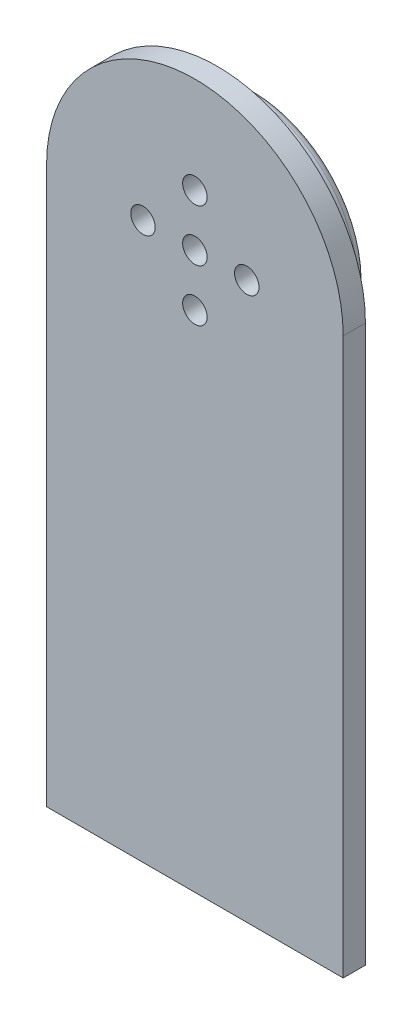
from build123d import *

# Parameters (mm, degrees)
SKETCH_1_R      = 15
SKETCH_1_R_2    = 1.65
EXTRUDE_1_DEPTH = 8
FILLET_1_R      = 1
EXTRUDE_2_DEPTH = 3


with BuildPart() as part:
    # 草图1 → 凸台-拉伸1 (new body)
    with BuildSketch(Plane.XY):
        Circle(SKETCH_1_R)
        Circle(SKETCH_1_R_2, mode=Mode.SUBTRACT)
        with Locations((0, 7)):
            Circle(SKETCH_1_R_2, mode=Mode.SUBTRACT)
        with Locations((7, 0)):
            Circle(SKETCH_1_R_2, mode=Mode.SUBTRACT)
        with Locations((0, -7)):
            Circle(SKETCH_1_R_2, mode=Mode.SUBTRACT)
        with Locations((-7, 0)):
            Circle(SKETCH_1_R_2, mode=Mode.SUBTRACT)
    extrude(amount=EXTRUDE_1_DEPTH)

    # 圆角1
    fillet_1_edges = [part.edges().sort_by_distance(p)[0] for p in [
        (-15, 0, 0),
    ]]
    fillet(fillet_1_edges, radius=FILLET_1_R)

    # 草图2 → 凸台-拉伸2 (add)
    with BuildSketch(Plane.XY.offset(8)):
        with BuildLine():
            ThreePointArc((-15, 0), (0, 15), (15, 0))
            Line((15, 0), (20, 0))
            ThreePointArc((20, 0), (0, 20), (-20, 0))
            Line((-20, 0), (-15, 0))
        make_face()
        with BuildLine():
            Line((20, 0), (15, 0))
            ThreePointArc((15, 0), (0, -15), (-15, 0))
            Line((-15, 0), (-20, 0))
            ThreePointArc((-20, 0), (0, -20), (20, 0))
        make_face()
        with BuildLine():
            Line((20, -75), (20, 0))
            ThreePointArc((20, 0), (0, -20), (-20, 0))
            Line((-20, 0), (-20, -75))
            Line((-20, -75), (20, -75))
        make_face()
    extrude(amount=-EXTRUDE_2_DEPTH)


solid = part.part
